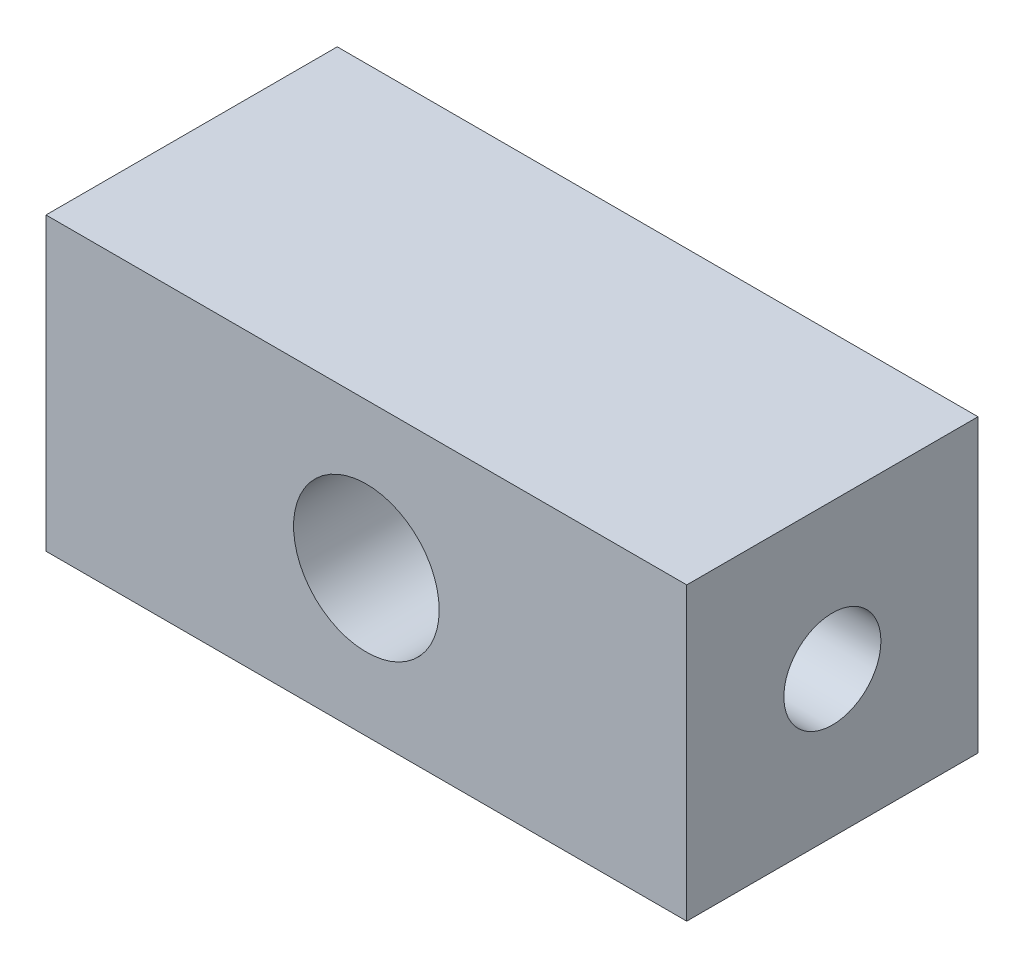
from build123d import *

# Parameters (mm, degrees)
CROQUIS1_W              = 66
CROQUIS1_H              = 30
CROQUIS1_R              = 7.5
SALIENTE_EXTRUIR1_DEPTH = 15
CROQUIS2_R              = 5
CORTAR_EXTRUIR1_DEPTH   = 67


with BuildPart() as part:
    # Croquis1 → Saliente-Extruir1 (new body, symmetric)
    with BuildSketch(Plane.XY):
        Rectangle(CROQUIS1_W, CROQUIS1_H)
        Circle(CROQUIS1_R, mode=Mode.SUBTRACT)
    extrude(amount=SALIENTE_EXTRUIR1_DEPTH, both=True)

    # Croquis2 → Cortar-Extruir1 (cut, through all)
    with BuildSketch(Plane(origin=(33, 0, 0), x_dir=(0, 0, -1), z_dir=(1, 0, 0))):
        Circle(CROQUIS2_R)
    extrude(amount=-CORTAR_EXTRUIR1_DEPTH, mode=Mode.SUBTRACT)


solid = part.part
